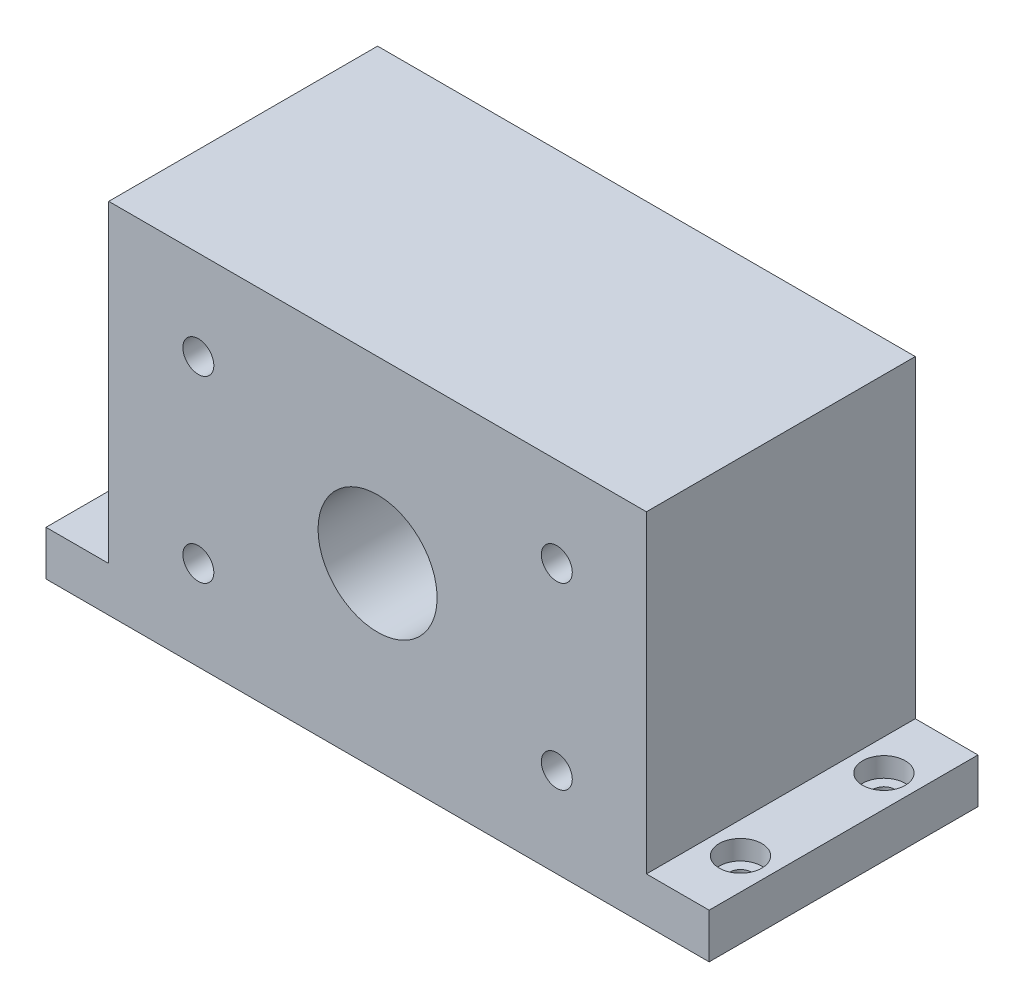
from build123d import *

# Parameters (mm, degrees)
SKETCH5_W                                      = 60
SKETCH5_H                                      = 30
BOSS_EXTRUDE3_DEPTH                            = 40
SKETCH7_W                                      = 40
SKETCH7_H                                      = 20
CUT_EXTRUDE1_DEPTH                             = 15
FILLET1_R                                      = 3
FILLET2_R                                      = 3
FILLET3_R                                      = 3
FILLET4_R                                      = 3
SKETCH9_W                                      = 30
SKETCH9_H                                      = 5
BOSS_EXTRUDE4_DEPTH                            = 7
SKETCH10_W                                     = 30
SKETCH10_H                                     = 5
BOSS_EXTRUDE5_DEPTH                            = 7
SKETCH12_R                                     = 2
CUT_EXTRUDE2_DEPTH                             = 10
SKETCH13_W                                     = 64
SKETCH13_H                                     = 20
CUT_EXTRUDE3_DEPTH                             = 1.5
F_2_56_TAPPED_HOLE2_D                          = 1.778
F_2_56_TAPPED_HOLE2_DEPTH                      = 15
F_2_56_TAPPED_HOLE2_TIP                        = 0.53416509
F_2_56_TAPPED_HOLE3_D                          = 1.778
F_2_56_TAPPED_HOLE3_DEPTH                      = 15
F_2_56_TAPPED_HOLE3_TIP                        = 0.53416509
CBORE_FOR_2_SOCKET_HEAD_CAP_SCREW3_D           = 2.4384
CBORE_FOR_2_SOCKET_HEAD_CAP_SCREW3_DEPTH       = 15
CBORE_FOR_2_SOCKET_HEAD_CAP_SCREW3_CBORE_D     = 4.7625
CBORE_FOR_2_SOCKET_HEAD_CAP_SCREW3_CBORE_DEPTH = 2.1844
CBORE_FOR_2_SOCKET_HEAD_CAP_SCREW3_TIP         = 0.732569267
F_8_32_TAPPED_HOLE1_D                          = 3.4544
F_8_32_TAPPED_HOLE1_DEPTH                      = 11
F_8_32_TAPPED_HOLE1_TIP                        = 1.037806461
F_0_535_40_TAPPED_HOLE1_D                      = 13.2842
SKETCH30_R                                     = 1.5
SKETCH30_R_2                                   = 3
CUT_EXTRUDE5_DEPTH                             = 10
CBORE_FOR_2_SOCKET_HEAD_CAP_SCREW4_D           = 2.4384
CBORE_FOR_2_SOCKET_HEAD_CAP_SCREW4_CBORE_D     = 4.7625
CBORE_FOR_2_SOCKET_HEAD_CAP_SCREW4_CBORE_DEPTH = 2.1844


with BuildPart() as part:
    # Sketch5 → Boss-Extrude3 (new body)
    with BuildSketch(Plane(origin=(0, 0, 0), x_dir=(1, 0, 0), z_dir=(0, 1, 0))):
        Rectangle(SKETCH5_W, SKETCH5_H)
    extrude(amount=BOSS_EXTRUDE3_DEPTH)

    # Sketch7 → Cut-Extrude1 (cut)
    with BuildSketch(Plane(origin=(0, 0, -15), x_dir=(-1, 0, 0), z_dir=(0, 0, -1))):
        with Locations((0, 20)):
            Rectangle(SKETCH7_W, SKETCH7_H)
    extrude(amount=-CUT_EXTRUDE1_DEPTH, mode=Mode.SUBTRACT)

    # Fillet1
    fillet1_edges = [part.edges().sort_by_distance(p)[0] for p in [
        (20, 10, -7.5),
    ]]
    fillet(fillet1_edges, radius=FILLET1_R)

    # Fillet2
    fillet2_edges = [part.edges().sort_by_distance(p)[0] for p in [
        (-20, 10, -7.5),
    ]]
    fillet(fillet2_edges, radius=FILLET2_R)

    # Fillet3
    fillet3_edges = [part.edges().sort_by_distance(p)[0] for p in [
        (-20, 30, -7.5),
    ]]
    fillet(fillet3_edges, radius=FILLET3_R)

    # Fillet4
    fillet4_edges = [part.edges().sort_by_distance(p)[0] for p in [
        (20, 30, -7.5),
    ]]
    fillet(fillet4_edges, radius=FILLET4_R)

    # Sketch9 → Boss-Extrude4 (add)
    with BuildSketch(Plane.ZY.offset(30)):
        with Locations((0, 2.5)):
            Rectangle(SKETCH9_W, SKETCH9_H)
    extrude(amount=BOSS_EXTRUDE4_DEPTH)

    # Sketch10 → Boss-Extrude5 (add)
    with BuildSketch(Plane(origin=(30, 0, 0), x_dir=(0, 0, -1), z_dir=(1, 0, 0))):
        with Locations((0, 2.5)):
            Rectangle(SKETCH10_W, SKETCH10_H)
    extrude(amount=BOSS_EXTRUDE5_DEPTH)

    # Sketch12 → Cut-Extrude2 (cut)
    with BuildSketch(Plane.ZY.offset(30)):
        with Locations((-7.531524718, 22.710545663)):
            Circle(SKETCH12_R)
    extrude(amount=-CUT_EXTRUDE2_DEPTH, mode=Mode.SUBTRACT)

    # Sketch13 → Cut-Extrude3 (cut)
    with BuildSketch(Plane(origin=(0, 0, 0), x_dir=(-1, 0, 0), z_dir=(0, -1, 0))):
        Rectangle(SKETCH13_W, SKETCH13_H)
    extrude(amount=-CUT_EXTRUDE3_DEPTH, mode=Mode.SUBTRACT)

    # #2-56 Tapped Hole2
    with Locations(Plane(origin=(25, 36, -15), x_dir=(-1, 0, 0), z_dir=(0, 0, -1))):
        with Locations((0, 0), (0, -32), (50, -32)):
            Hole(F_2_56_TAPPED_HOLE2_D / 2, depth=F_2_56_TAPPED_HOLE2_DEPTH)
            with Locations((0, 0, -(F_2_56_TAPPED_HOLE2_DEPTH + F_2_56_TAPPED_HOLE2_TIP / 2))):  # 118° drill point
                Cone(0, F_2_56_TAPPED_HOLE2_D / 2, F_2_56_TAPPED_HOLE2_TIP, mode=Mode.SUBTRACT)

    # #2-56 Tapped Hole3
    with Locations(Plane(origin=(-25, 36, -15), x_dir=(-1, 0, 0), z_dir=(0, 0, -1))):
        with Locations((0, 0)):
            Hole(F_2_56_TAPPED_HOLE3_D / 2, depth=F_2_56_TAPPED_HOLE3_DEPTH)
            with Locations((0, 0, -(F_2_56_TAPPED_HOLE3_DEPTH + F_2_56_TAPPED_HOLE3_TIP / 2))):  # 118° drill point
                Cone(0, F_2_56_TAPPED_HOLE3_D / 2, F_2_56_TAPPED_HOLE3_TIP, mode=Mode.SUBTRACT)

    # CBORE for #2 Socket Head Cap Screw3
    with Locations(Plane(origin=(0, 5, 0), x_dir=(1, 0, 0), z_dir=(0, 1, 0))):
        with Locations((-33.5, 8), (-33.5, -8)):
            CounterBoreHole(CBORE_FOR_2_SOCKET_HEAD_CAP_SCREW3_D / 2, CBORE_FOR_2_SOCKET_HEAD_CAP_SCREW3_CBORE_D / 2, CBORE_FOR_2_SOCKET_HEAD_CAP_SCREW3_CBORE_DEPTH, depth=CBORE_FOR_2_SOCKET_HEAD_CAP_SCREW3_DEPTH)
            with Locations((0, 0, -(CBORE_FOR_2_SOCKET_HEAD_CAP_SCREW3_DEPTH + CBORE_FOR_2_SOCKET_HEAD_CAP_SCREW3_TIP / 2))):  # 118° drill point
                Cone(0, CBORE_FOR_2_SOCKET_HEAD_CAP_SCREW3_D / 2, CBORE_FOR_2_SOCKET_HEAD_CAP_SCREW3_TIP, mode=Mode.SUBTRACT)

    # #8-32 Tapped Hole1
    with Locations(Plane.XY.offset(15)):
        with Locations((-20, 30), (-20, 10), (20, 10), (20, 30)):
            Hole(F_8_32_TAPPED_HOLE1_D / 2, depth=F_8_32_TAPPED_HOLE1_DEPTH)
            with Locations((0, 0, -(F_8_32_TAPPED_HOLE1_DEPTH + F_8_32_TAPPED_HOLE1_TIP / 2))):  # 118° drill point
                Cone(0, F_8_32_TAPPED_HOLE1_D / 2, F_8_32_TAPPED_HOLE1_TIP, mode=Mode.SUBTRACT)

    # 0.535-40 Tapped Hole1 (through all)
    with Locations(Plane(origin=(0, 20, 0), x_dir=(-1, 0, 0), z_dir=(0, 0, -1))):
        with Locations((0, 0)):
            Hole(F_0_535_40_TAPPED_HOLE1_D / 2)

    # Sketch30 → Cut-Extrude5 (cut)
    with BuildSketch(Plane(origin=(0, 0, 0), x_dir=(-1, 0, 0), z_dir=(0, 0, -1))):
        with Locations((-12.5, 20)):
            Circle(SKETCH30_R)
        with Locations((12.5, 20)):
            Circle(SKETCH30_R_2)
    extrude(amount=-CUT_EXTRUDE5_DEPTH, mode=Mode.SUBTRACT)

    # CBORE for #2 Socket Head Cap Screw4 (through all)
    with Locations(Plane(origin=(33.5, 5, 8), x_dir=(0, 0, 1), z_dir=(0, 1, 0))):
        with Locations((0, 0), (-16, 0)):
            CounterBoreHole(CBORE_FOR_2_SOCKET_HEAD_CAP_SCREW4_D / 2, CBORE_FOR_2_SOCKET_HEAD_CAP_SCREW4_CBORE_D / 2, CBORE_FOR_2_SOCKET_HEAD_CAP_SCREW4_CBORE_DEPTH)


solid = part.part
